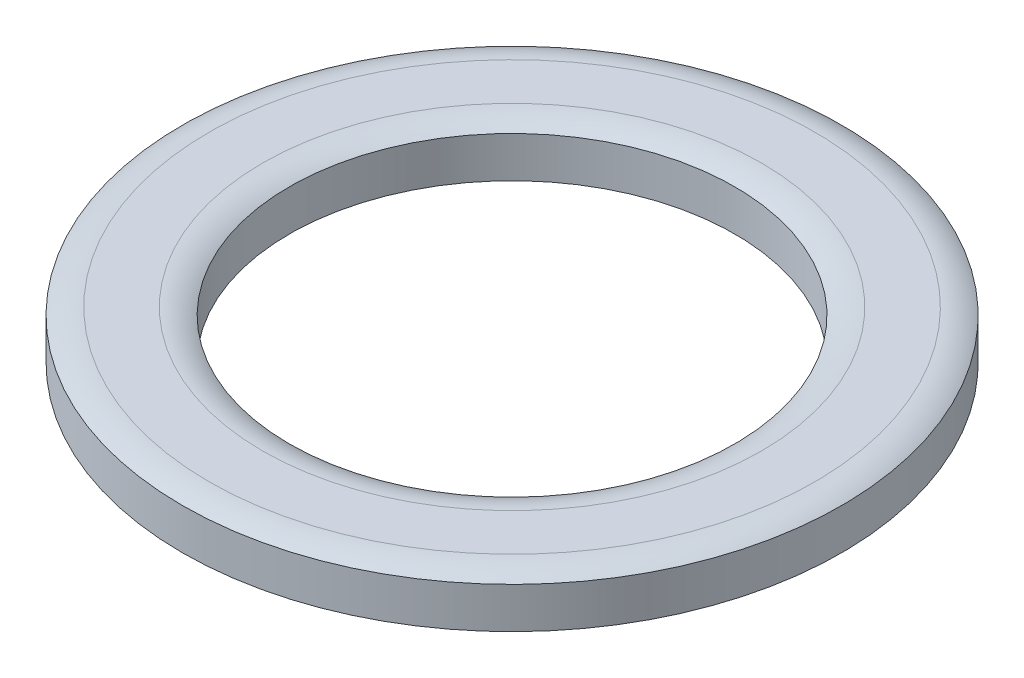
from build123d import *


with BuildPart() as part:
    # Sketch3 → Revolve1 (revolve)
    with BuildSketch(Plane(origin=(0, 0, 0), x_dir=(0, 0, -1), z_dir=(1, 0, 0))):
        with BuildLine():
            Line((5.5626, -0.4064), (3.7592, -0.4064))
            Line((3.7592, -0.4064), (3.7592, 0.28448))
            ThreePointArc((3.7592, 0.28448), (3.976527941, 0.375382251), (4.21005, 0.4064))
            Line((4.21005, 0.4064), (5.11175, 0.4064))
            ThreePointArc((5.11175, 0.4064), (5.345272059, 0.375382251), (5.5626, 0.28448))
            Line((5.5626, 0.28448), (5.5626, -0.4064))
        make_face()
    revolve(axis=Axis((0, 0.4064, 0), (0, -1, 0)))


solid = part.part
